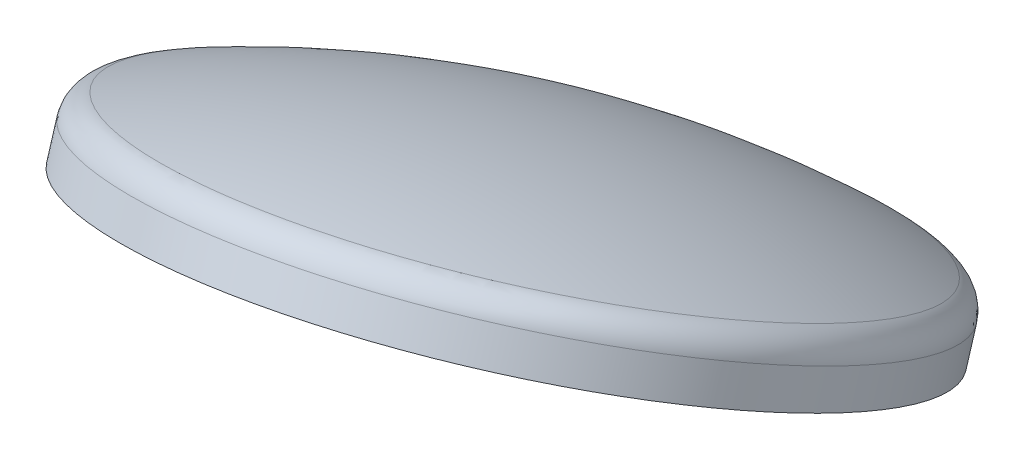
from build123d import *


with BuildPart() as part:
    # Sketch1 → Revolve1 (revolve)
    with BuildSketch(Plane(origin=(-170.126510157, -378.462559963, 173.892254674), x_dir=(-0.12417271401547268, 0.39709903879718633, 0.9093368410442757), z_dir=(-0.9865371296335288, -0.1476957156883053, -0.07021728720021364))):
        with BuildLine():
            Line((201.413414743, 456.277858032), (201.413414743, 478.603217986))
            ThreePointArc((201.413414743, 478.603217986), (197.844782275, 489.70410801), (188.475907203, 496.645943277))
            ThreePointArc((188.475907203, 496.645943277), (81.221954161, 523.459876529), (-28.964585257, 532.477858032))
            Line((-28.964585257, 532.477858032), (-28.964585257, 535.652858032))
            ThreePointArc((-28.964585257, 535.652858032), (82.894207472, 526.401105506), (191.712975822, 498.897285948))
            ThreePointArc((191.712975822, 498.897285948), (201.038864552, 491.949936692), (204.588414743, 480.875707341))
            Line((204.588414743, 480.875707341), (204.588414743, 456.277858032))
            Line((204.588414743, 456.277858032), (201.413414743, 456.277858032))
        make_face()
    revolve(axis=Axis((-223.535114395, 95.237289839, -72.113649338), (0.10642193828561908, -0.9058136281563032, 0.410092723780667)))


solid = part.part
